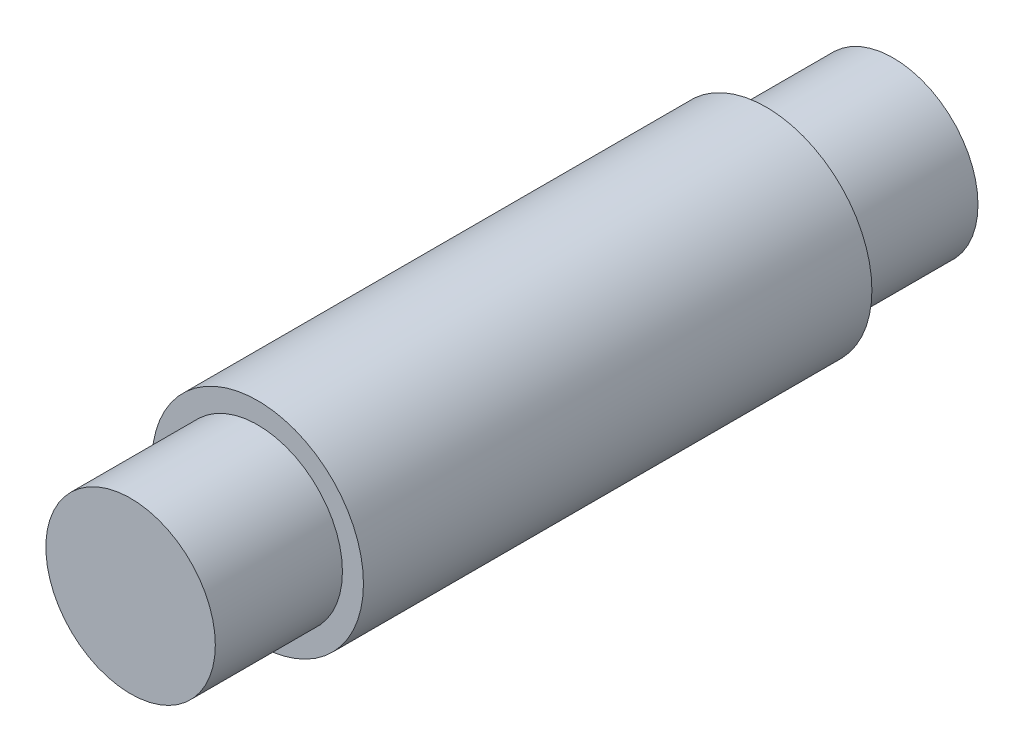
from build123d import *

# Parameters (mm, degrees)
SKETCH1_R           = 3.9624
BOSS_EXTRUDE1_DEPTH = 9.525
SKETCH2_R           = 3.175
BOSS_EXTRUDE2_DEPTH = 14.2875


with BuildPart() as part:
    # Sketch1 → Boss-Extrude1 (new body, symmetric)
    with BuildSketch(Plane.XY):
        Circle(SKETCH1_R)
    extrude(amount=BOSS_EXTRUDE1_DEPTH, both=True)

    # Sketch2 → Boss-Extrude2 (add, symmetric)
    with BuildSketch(Plane.XY):
        Circle(SKETCH2_R)
    extrude(amount=BOSS_EXTRUDE2_DEPTH, both=True)


solid = part.part
